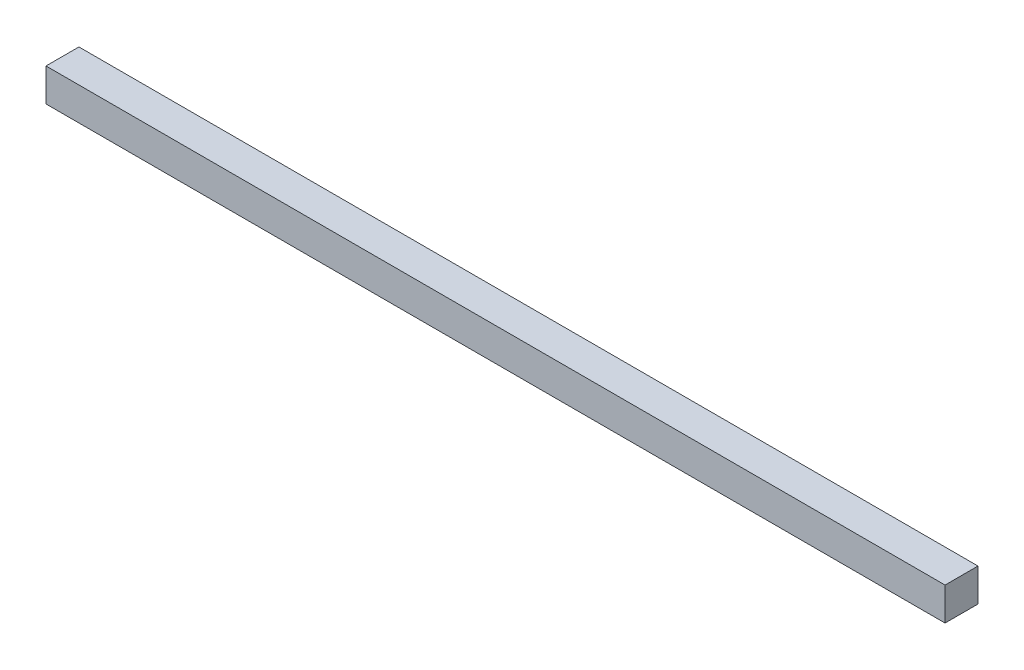
from build123d import *

# Parameters (mm, degrees)
ESQUISSE1_W        = 273
ESQUISSE1_H        = 10
BOSS_EXTRU_1_DEPTH = 10


with BuildPart() as part:
    # Esquisse1 → Boss.-Extru.1 (new body)
    with BuildSketch(Plane.XY):
        with Locations((48.907296651, 40.545454545)):
            Rectangle(ESQUISSE1_W, ESQUISSE1_H)
    extrude(amount=BOSS_EXTRU_1_DEPTH)


solid = part.part
